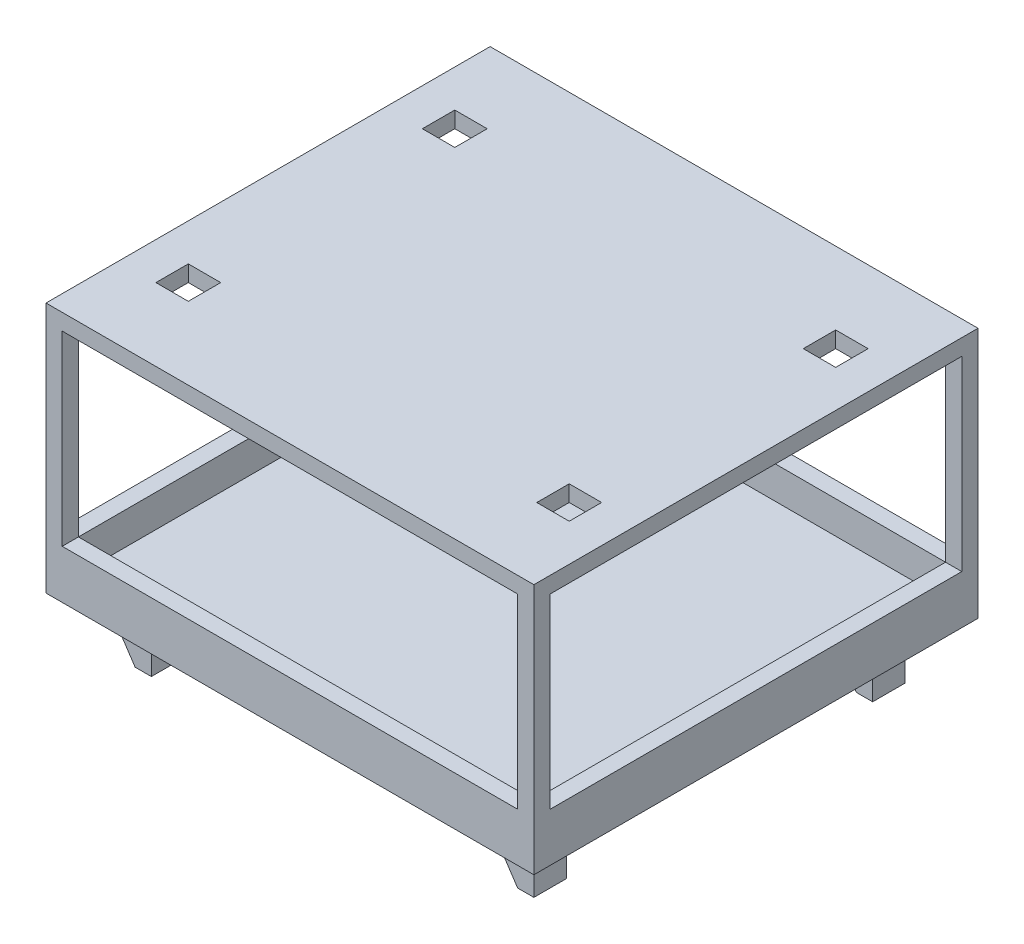
from build123d import *

# Parameters (mm, degrees)
SKETCH1_W           = 76.454
SKETCH1_H           = 69.596
BOSS_EXTRUDE1_DEPTH = 7.62
SKETCH2_W           = 71.374
SKETCH2_H           = 64.516
CUT_EXTRUDE1_DEPTH  = 5.08
SKETCH4_W           = 5.08
SKETCH4_H           = 5.08
BOSS_EXTRUDE2_DEPTH = 8.7884
CUT_EXTRUDE2_DEPTH  = 5.08
SKETCH6_W           = 2.54
SKETCH6_H           = 2.54
BOSS_EXTRUDE3_DEPTH = 29.21
SKETCH7_W           = 76.454
SKETCH7_H           = 69.596
BOSS_EXTRUDE4_DEPTH = 2.54
CUT_EXTRUDE3_REACH  = 50.158
SKETCH8_W           = 5.08
SKETCH8_H           = 5.08


with BuildPart() as part:
    # Sketch1 → Boss-Extrude1 (new body)
    with BuildSketch(Plane(origin=(0, 0, 0), x_dir=(1, 0, 0), z_dir=(0, 1, 0))):
        Rectangle(SKETCH1_W, SKETCH1_H)
    extrude(amount=-BOSS_EXTRUDE1_DEPTH)

    # Sketch2 → Cut-Extrude1 (cut)
    with BuildSketch(Plane(origin=(0, 0, 0), x_dir=(1, 0, 0), z_dir=(0, 1, 0))):
        Rectangle(SKETCH2_W, SKETCH2_H)
    extrude(amount=-CUT_EXTRUDE1_DEPTH, mode=Mode.SUBTRACT)

    # Sketch4 → Boss-Extrude2 (add)
    with BuildSketch(Plane.XZ.offset(7.62)):
        with Locations((-29.972, 26.543)):
            Rectangle(SKETCH4_W, SKETCH4_H)
        with Locations((29.972, 26.543)):
            Rectangle(SKETCH4_W, SKETCH4_H)
    boss_extrude2 = extrude(amount=BOSS_EXTRUDE2_DEPTH)

    # Sketch5 → Cut-Extrude2 (cut)
    with BuildSketch(Plane.XY.offset(29.083)):
        Polygon((29.972, -16.4084), (27.432, -12.606876095), (27.432, -16.4084), align=None)
        Polygon((-29.972, -16.4084), (-32.512, -12.606876095), (-32.512, -16.4084), align=None)
        Polygon((27.432, -11.336876095), (29.153074553, -10.798216701), (29.153074553, -7.62), (27.432, -7.62), align=None)
        Polygon((-32.512, -11.336876095), (-30.790925447, -10.798216701), (-30.790925447, -7.62), (-32.512, -7.62), align=None)
    cut_extrude2 = extrude(amount=-CUT_EXTRUDE2_DEPTH, mode=Mode.SUBTRACT)

    # Mirror1: Boss-Extrude2, Cut-Extrude2 across plane
    add(boss_extrude2.mirror(Plane.XY))
    add(cut_extrude2.mirror(Plane.XY), mode=Mode.SUBTRACT)

    # Sketch6 → Boss-Extrude3 (add)
    with BuildSketch(Plane(origin=(0, 0, 0), x_dir=(1, 0, 0), z_dir=(0, 1, 0))):
        with Locations((-36.957, 33.528)):
            Rectangle(SKETCH6_W, SKETCH6_H)
        with Locations((-36.957, -33.528)):
            Rectangle(SKETCH6_W, SKETCH6_H)
        with Locations((36.957, -33.528)):
            Rectangle(SKETCH6_W, SKETCH6_H)
        with Locations((36.957, 33.528)):
            Rectangle(SKETCH6_W, SKETCH6_H)
    extrude(amount=BOSS_EXTRUDE3_DEPTH)

    # Sketch7 → Boss-Extrude4 (add)
    with BuildSketch(Plane(origin=(0, 29.21, 0), x_dir=(1, 0, 0), z_dir=(0, 1, 0))):
        Rectangle(SKETCH7_W, SKETCH7_H)
    extrude(amount=BOSS_EXTRUDE4_DEPTH)

    # Sketch8 → Cut-Extrude3 (cut, up to next)
    with BuildSketch(Plane(origin=(0, 31.75, 0), x_dir=(1, 0, 0), z_dir=(0, 1, 0)), mode=Mode.PRIVATE) as cut_extrude3_sk1:
        with Locations((29.845, 20.8788)):
            Rectangle(SKETCH8_W, SKETCH8_H)
    cut_extrude3_tool1 = extrude(cut_extrude3_sk1.sketch, amount=-CUT_EXTRUDE3_REACH, mode=Mode.PRIVATE) & part.part
    add(cut_extrude3_tool1.solids().sort_by_distance((29.845, 31.75, -20.8788))[0], mode=Mode.SUBTRACT)
    # Sketch8 → Cut-Extrude3 (cut, up to next)
    with BuildSketch(Plane(origin=(0, 31.75, 0), x_dir=(1, 0, 0), z_dir=(0, 1, 0)), mode=Mode.PRIVATE) as cut_extrude3_sk2:
        with Locations((-29.845, 20.8788)):
            Rectangle(SKETCH8_W, SKETCH8_H)
    cut_extrude3_tool2 = extrude(cut_extrude3_sk2.sketch, amount=-CUT_EXTRUDE3_REACH, mode=Mode.PRIVATE) & part.part
    add(cut_extrude3_tool2.solids().sort_by_distance((-29.845, 31.75, -20.8788))[0], mode=Mode.SUBTRACT)
    # Sketch8 → Cut-Extrude3 (cut, up to next)
    with BuildSketch(Plane(origin=(0, 31.75, 0), x_dir=(1, 0, 0), z_dir=(0, 1, 0)), mode=Mode.PRIVATE) as cut_extrude3_sk3:
        with Locations((29.845, -20.8788)):
            Rectangle(SKETCH8_W, SKETCH8_H)
    cut_extrude3_tool3 = extrude(cut_extrude3_sk3.sketch, amount=-CUT_EXTRUDE3_REACH, mode=Mode.PRIVATE) & part.part
    add(cut_extrude3_tool3.solids().sort_by_distance((29.845, 31.75, 20.8788))[0], mode=Mode.SUBTRACT)
    # Sketch8 → Cut-Extrude3 (cut, up to next)
    with BuildSketch(Plane(origin=(0, 31.75, 0), x_dir=(1, 0, 0), z_dir=(0, 1, 0)), mode=Mode.PRIVATE) as cut_extrude3_sk4:
        with Locations((-29.845, -20.8788)):
            Rectangle(SKETCH8_W, SKETCH8_H)
    cut_extrude3_tool4 = extrude(cut_extrude3_sk4.sketch, amount=-CUT_EXTRUDE3_REACH, mode=Mode.PRIVATE) & part.part
    add(cut_extrude3_tool4.solids().sort_by_distance((-29.845, 31.75, 20.8788))[0], mode=Mode.SUBTRACT)


solid = part.part
